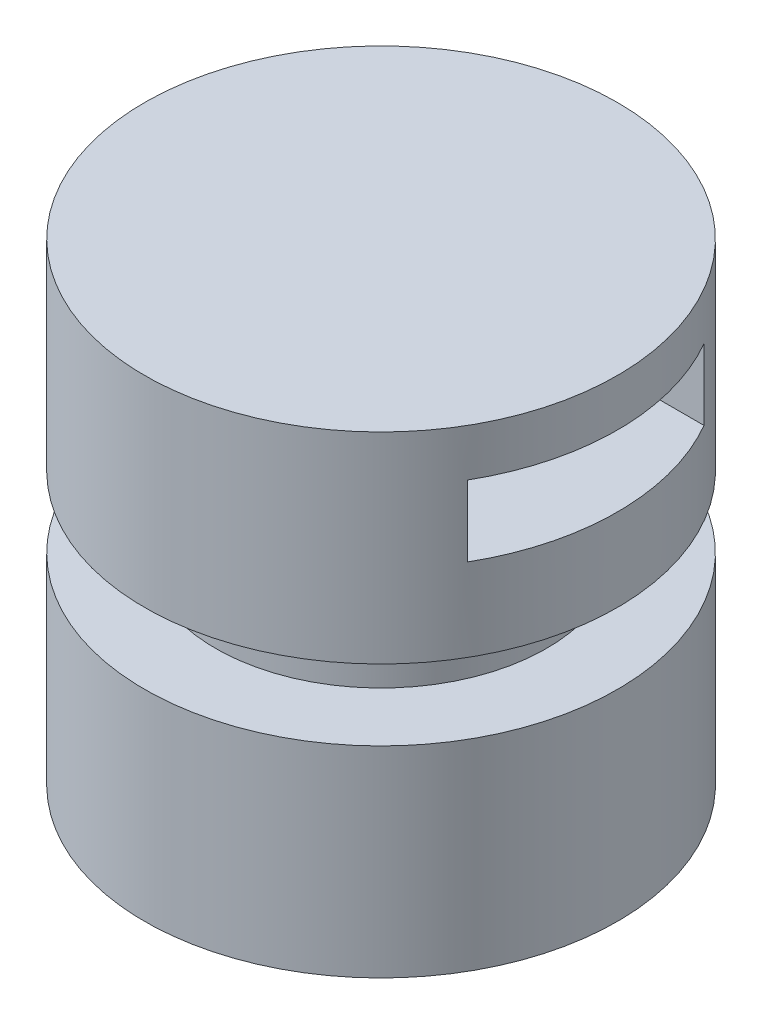
from build123d import *

# Parameters (mm, degrees)
SKETCH1_W               = 100
SKETCH1_H               = 200
SKETCH2_W               = 30
SKETCH2_H               = 15
SKETCH3_W               = 100
SKETCH3_H               = 30
CUT_EXTRUDE1_DEPTH      = 101
CUT_EXTRUDE1_DEPTH_BACK = 101


with BuildPart() as part:
    # Sketch1 → Revolve1 (revolve)
    with BuildSketch(Plane.XY):
        with Locations((50, 100)):
            Rectangle(SKETCH1_W, SKETCH1_H)
    revolve(axis=Axis((0, 0, 0), (0, 1, 0)))

    # Sketch2 → Cut-Revolve1 (revolve, cut)
    with BuildSketch(Plane(origin=(0, 0, 0), x_dir=(0, 0, -1), z_dir=(1, 0, 0))):
        with Locations((85, 92.5)):
            Rectangle(SKETCH2_W, SKETCH2_H)
        with Locations((85, 107.5)):
            Rectangle(SKETCH2_W, SKETCH2_H)
    revolve(axis=Axis((0, 200, 0), (0, -1, 0)), mode=Mode.SUBTRACT)

    # Sketch3 → Cut-Extrude1 (cut, two sides)
    with BuildSketch(Plane(origin=(0, 0, 0), x_dir=(0, 0, -1), z_dir=(1, 0, 0))) as cut_extrude1_sk:
        with Locations((0, 165)):
            Rectangle(SKETCH3_W, SKETCH3_H)
    extrude(amount=CUT_EXTRUDE1_DEPTH, mode=Mode.SUBTRACT)
    extrude(cut_extrude1_sk.sketch, amount=-CUT_EXTRUDE1_DEPTH_BACK, mode=Mode.SUBTRACT)


solid = part.part
